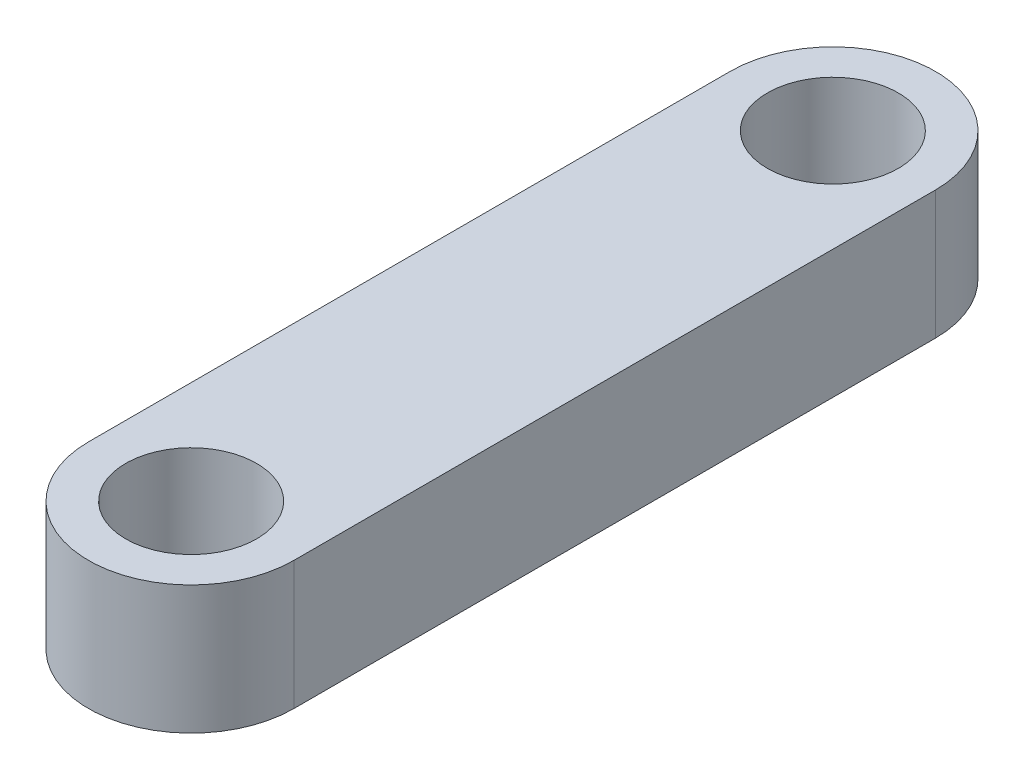
from build123d import *

# Parameters (mm, degrees)
BOSS_EXTRUDE1_DEPTH = 5
SKETCH2_R           = 2.55
CUT_EXTRUDE2_DEPTH  = 6


with BuildPart() as part:
    # Sketch1 → Boss-Extrude1 (new body)
    with BuildSketch(Plane(origin=(0, 0, 0), x_dir=(1, 0, 0), z_dir=(0, 1, 0))):
        with BuildLine():
            Line((-4, -12.5), (-4, 12.5))
            ThreePointArc((-4, 12.5), (0, 16.5), (4, 12.5))
            Line((4, 12.5), (4, -12.5))
            ThreePointArc((4, -12.5), (0, -16.5), (-4, -12.5))
        make_face()
    extrude(amount=BOSS_EXTRUDE1_DEPTH)

    # Sketch2 → Cut-Extrude2 (cut, through all)
    with BuildSketch(Plane(origin=(0, 5, 0), x_dir=(1, 0, 0), z_dir=(0, 1, 0))):
        with Locations((0, 12.5)):
            Circle(SKETCH2_R)
        with Locations((0, -12.5)):
            Circle(SKETCH2_R)
    extrude(amount=-CUT_EXTRUDE2_DEPTH, mode=Mode.SUBTRACT)


solid = part.part
